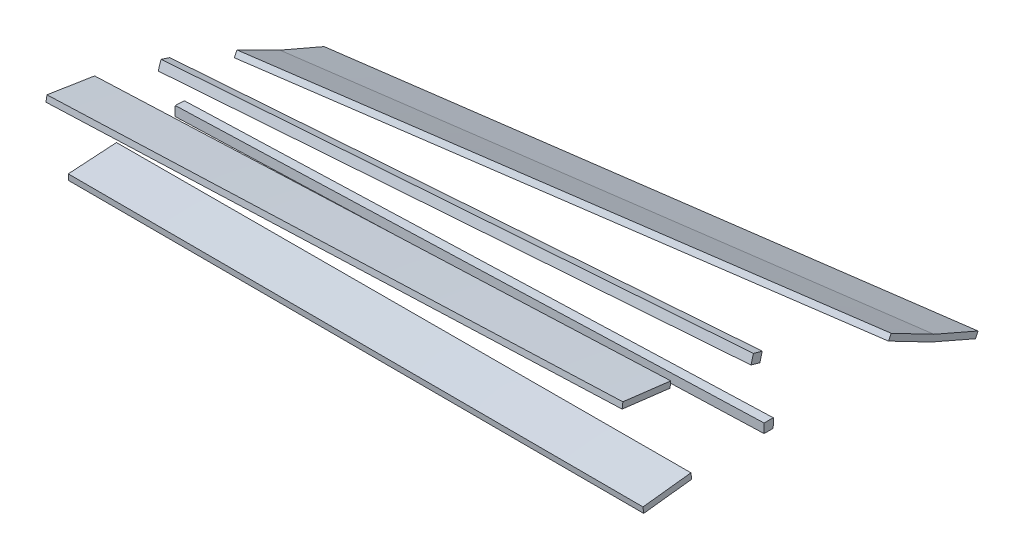
from build123d import *


with BuildPart() as part:
    # Sketch1 → Loft1 section 0
    with BuildSketch(Plane(origin=(0, 0, 0), x_dir=(0, 0, -1), z_dir=(1, 0, 0))):
        Polygon((5.924524399, -3.873191473), (31.13772874, -6.947980383), (31.522077354, -3.79632984), (6.308873012, -0.72154093), align=None)
    # Sketch2 → Loft1 section 1
    with BuildSketch(Plane(origin=(-301.244, 0, 0), x_dir=(0, 0, -1), z_dir=(1, 0, 0))):
        Polygon((29.66416581, -14.543476344), (4.571250508, -10.60576106), (4.079036097, -13.742375473), (29.171951399, -17.680090757), align=None)
    loft()


with BuildPart() as body_2:
    # Sketch1_3 → Loft2 section 0
    with BuildSketch(Plane(origin=(0, 0, 0), x_dir=(0, 0, -1), z_dir=(1, 0, 0))):
        Polygon((73.722592843, -17.689285792), (78.376128634, -18.967910303), (79.654753145, -14.314374511), (75.001217353, -13.035750001), align=None)
    # Sketch2_3 → Loft2 section 1
    with BuildSketch(Plane(origin=(-301.244, 0, 0), x_dir=(0, 0, -1), z_dir=(1, 0, 0))):
        Polygon((67.679850957, -30.564309841), (63.101919005, -29.03695427), (64.629274577, -24.459022317), (69.207206529, -25.986377889), align=None)
    loft()


with BuildPart() as body_3:
    # Sketch1_4 → Loft3 section 0
    with BuildSketch(Plane(origin=(0, 0, 0), x_dir=(0, 0, -1), z_dir=(1, 0, 0))):
        Polygon((146.053031758, -42.941582115), (168.594795862, -54.647515272), (170.058037507, -51.829794759), (147.516273403, -40.123861602), align=None)
    # Sketch2_4 → Loft3 section 1
    with BuildSketch(Plane(origin=(-301.244, 0, 0), x_dir=(0, 0, -1), z_dir=(1, 0, 0))):
        Polygon((125.828368959, -54.427320521), (103.140917658, -43.006306842), (104.568544368, -40.17037543), (127.255995669, -51.591389108), align=None)
    loft()

    # Sketch1_5 → Loft4 section 0
    with BuildSketch(Plane(origin=(0, 0, 0), x_dir=(0, 0, -1), z_dir=(1, 0, 0))):
        Polygon((168.594795862, -54.647515272), (191.882473097, -64.788722746), (193.150124031, -61.877763092), (169.862446797, -51.736555617), align=None)
    # Sketch2_5 → Loft4 section 1
    with BuildSketch(Plane(origin=(-301.244, 0, 0), x_dir=(0, 0, -1), z_dir=(1, 0, 0))):
        Polygon((149.157729545, -64.472266247), (125.828368959, -54.427320521), (127.083987175, -51.511150448), (150.413347761, -61.556096174), align=None)
    loft()


with BuildPart() as body_4:
    # Sketch1_6 → Loft5 section 0
    with BuildSketch(Plane(origin=(0, 0, 0), x_dir=(0, 0, -1), z_dir=(1, 0, 0))):
        Polygon((80.606015408, -52.363936617), (85.432011787, -52.369848162), (85.437923333, -47.543851783), (80.611926953, -47.537940238), align=None)
    # Sketch2_8 → Loft5 section 1
    with BuildSketch(Plane(origin=(-301.244, 0, 0), x_dir=(0, 0, -1), z_dir=(1, 0, 0))):
        Polygon((76.656597753, -54.31319682), (71.836959606, -54.065478974), (72.084677452, -49.245840827), (76.904315599, -49.493558673), align=None)
    loft()


with BuildPart() as body_5:
    # Sketch1_7 → Loft6 section 0
    with BuildSketch(Plane(origin=(0, 0, 0), x_dir=(0, 0, -1), z_dir=(1, 0, 0))):
        Polygon((17.276227552, -57.065250581), (16.90927633, -53.911527099), (42.139064186, -50.975917325), (42.506015408, -54.129640807), align=None)
    # Sketch2_7 → Loft6 section 1
    with BuildSketch(Plane(origin=(-301.244, 0, 0), x_dir=(0, 0, -1), z_dir=(1, 0, 0))):
        Polygon((41.356959606, -53.811683647), (16.006708373, -55.400633756), (15.80808961, -52.231852352), (41.158340842, -50.642902243), align=None)
    loft()


solid = Compound([part.part, body_2.part, body_3.part, body_4.part, body_5.part])
